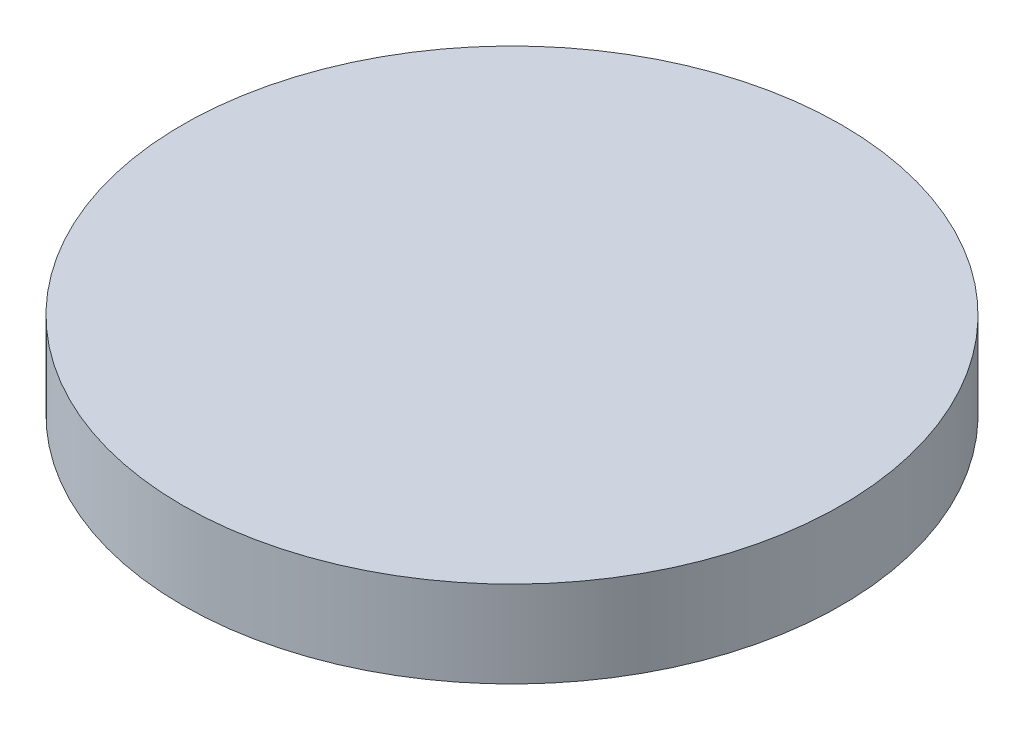
from build123d import *

# Parameters (mm, degrees)
SKETCH1_R           = 76.2
BOSS_EXTRUDE1_DEPTH = 20


with BuildPart() as part:
    # Sketch1 → Boss-Extrude1 (new body)
    with BuildSketch(Plane(origin=(0, 0, 0), x_dir=(1, 0, 0), z_dir=(0, 1, 0))):
        Circle(SKETCH1_R)
    extrude(amount=BOSS_EXTRUDE1_DEPTH)


solid = part.part
